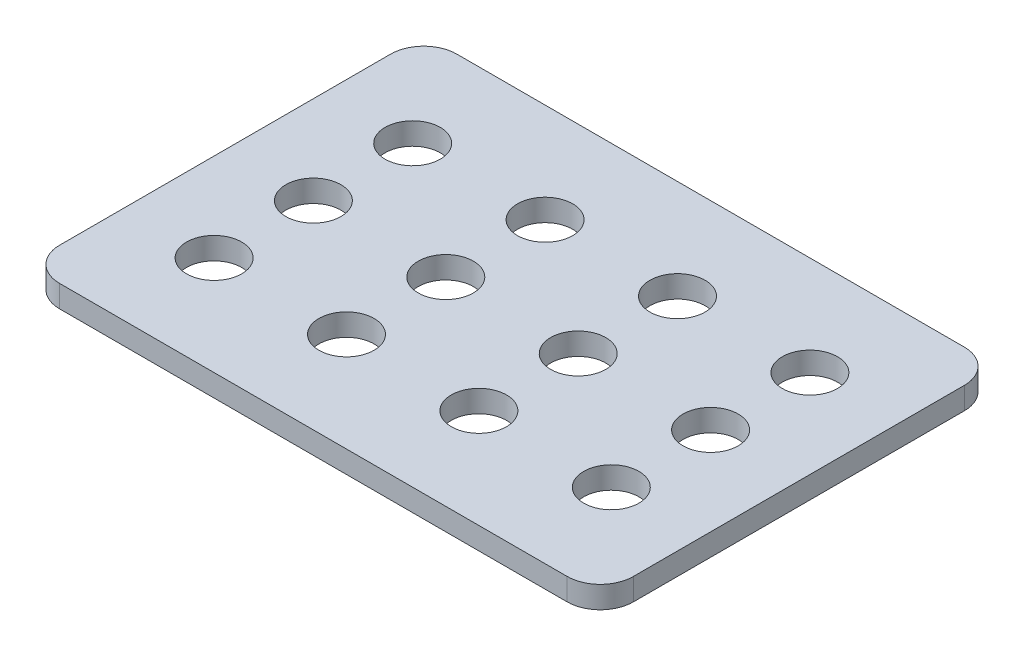
from build123d import *

# Parameters (mm, degrees)
SKETCH1_R           = 12.5
BOSS_EXTRUDE1_DEPTH = 5


with BuildPart() as part:
    # Sketch1 → Boss-Extrude1 (new body, symmetric)
    with BuildSketch(Plane(origin=(0, 0, 0), x_dir=(1, 0, 0), z_dir=(0, 1, 0))):
        with BuildLine():
            Line((-115, -90), (115, -90))
            ThreePointArc((115, -90), (125.606601718, -85.606601718), (130, -75))
            Line((130, -75), (130, 75))
            ThreePointArc((130, 75), (125.606601718, 85.606601718), (115, 90))
            Line((115, 90), (-115, 90))
            ThreePointArc((-115, 90), (-125.606601718, 85.606601718), (-130, 75))
            Line((-130, 75), (-130, -75))
            ThreePointArc((-130, -75), (-125.606601718, -85.606601718), (-115, -90))
        make_face()
        with Locations((-90, 45)):
            Circle(SKETCH1_R, mode=Mode.SUBTRACT)
        with Locations((-30, 45)):
            Circle(SKETCH1_R, mode=Mode.SUBTRACT)
        with Locations((30, 45)):
            Circle(SKETCH1_R, mode=Mode.SUBTRACT)
        with Locations((90, 45)):
            Circle(SKETCH1_R, mode=Mode.SUBTRACT)
        with Locations((-30, 0)):
            Circle(SKETCH1_R, mode=Mode.SUBTRACT)
        with Locations((30, 0)):
            Circle(SKETCH1_R, mode=Mode.SUBTRACT)
        with Locations((90, 0)):
            Circle(SKETCH1_R, mode=Mode.SUBTRACT)
        with Locations((-30, -45)):
            Circle(SKETCH1_R, mode=Mode.SUBTRACT)
        with Locations((30, -45)):
            Circle(SKETCH1_R, mode=Mode.SUBTRACT)
        with Locations((90, -45)):
            Circle(SKETCH1_R, mode=Mode.SUBTRACT)
        with Locations((-90, 0)):
            Circle(SKETCH1_R, mode=Mode.SUBTRACT)
        with Locations((-90, -45)):
            Circle(SKETCH1_R, mode=Mode.SUBTRACT)
    extrude(amount=BOSS_EXTRUDE1_DEPTH, both=True)


solid = part.part
